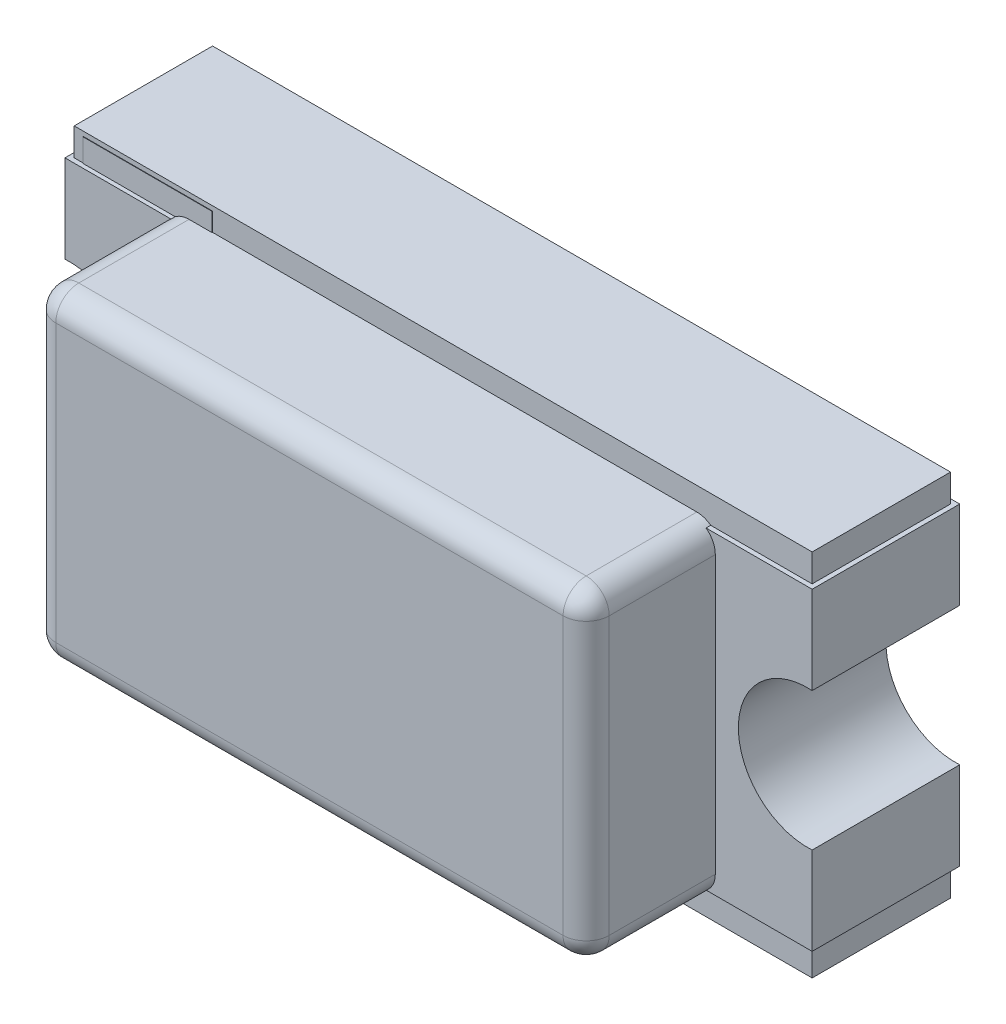
from build123d import *

# Parameters (mm, degrees)
EXTRUDE_START       = 0.01
SKETCH_2_W          = 1.6
SKETCH_2_H          = 0.8
EXTRUDE_1_DEPTH     = 0.3
SKETCH_3_W          = 0.31
SKETCH_3_H          = 0.68
EXTRUDE_2_DEPTH     = 0.32
EXTRUDE_START_2     = 0.3
SKETCH_4_W          = 1.2
SKETCH_4_H          = 0.7
EXTRUDE_3_DEPTH     = 0.3
FILLET_1_R          = 0.05
SKETCH_5_W          = 0.28
SKETCH_5_H          = 0.78
EXTRUDE_4_DEPTH     = 0.001
SKETCH_6_R          = 0.15
CUT_EXTRUDE_2_DEPTH = 0.52


with BuildPart() as part:
    # Эскиз2 → Бобышка-Вытянуть1 (new body)
    with BuildSketch(Plane.XY.offset(EXTRUDE_START)):
        Rectangle(SKETCH_2_W, SKETCH_2_H)
    extrude(amount=EXTRUDE_1_DEPTH)

    # Эскиз3 → Бобышка-Вытянуть2 (add)
    with BuildSketch(Plane.XY):
        with Locations((-0.655, 0)):
            Rectangle(SKETCH_3_W, SKETCH_3_H)
        with Locations((0.655, 0)):
            Rectangle(SKETCH_3_W, SKETCH_3_H)
    extrude(amount=EXTRUDE_2_DEPTH)

    # Эскиз4 → Бобышка-Вытянуть3 (add)
    with BuildSketch(Plane.XY.offset(EXTRUDE_START_2)):
        Rectangle(SKETCH_4_W, SKETCH_4_H)
    extrude(amount=EXTRUDE_3_DEPTH)

    # Скругление1
    fillet_1_edges = [part.edges().sort_by_distance(p)[0] for p in [
        (0.6, 0.35, 0.455),
        (-0.6, 0.35, 0.455),
        (0, 0.35, 0.6),
        (0.6, 0, 0.6),
        (0.6, -0.35, 0.455),
        (-0.6, -0.35, 0.455),
        (0, -0.35, 0.6),
        (-0.6, 0, 0.6),
    ]]
    fillet(fillet_1_edges, radius=FILLET_1_R)

    # Эскиз5 → Бобышка-Вытянуть4 (add)
    with BuildSketch(Plane.XY.offset(0.31)):
        with Locations((-0.64, 0)):
            Rectangle(SKETCH_5_W, SKETCH_5_H)
    extrude(amount=EXTRUDE_4_DEPTH)

    # Эскиз6 → Вырез-Вытянуть2 (cut)
    with BuildSketch(Plane.XY):
        with Locations((-0.8, 0)):
            Circle(SKETCH_6_R)
        with Locations((0.8, 0)):
            Circle(SKETCH_6_R)
    extrude(amount=CUT_EXTRUDE_2_DEPTH, mode=Mode.SUBTRACT)


solid = part.part
